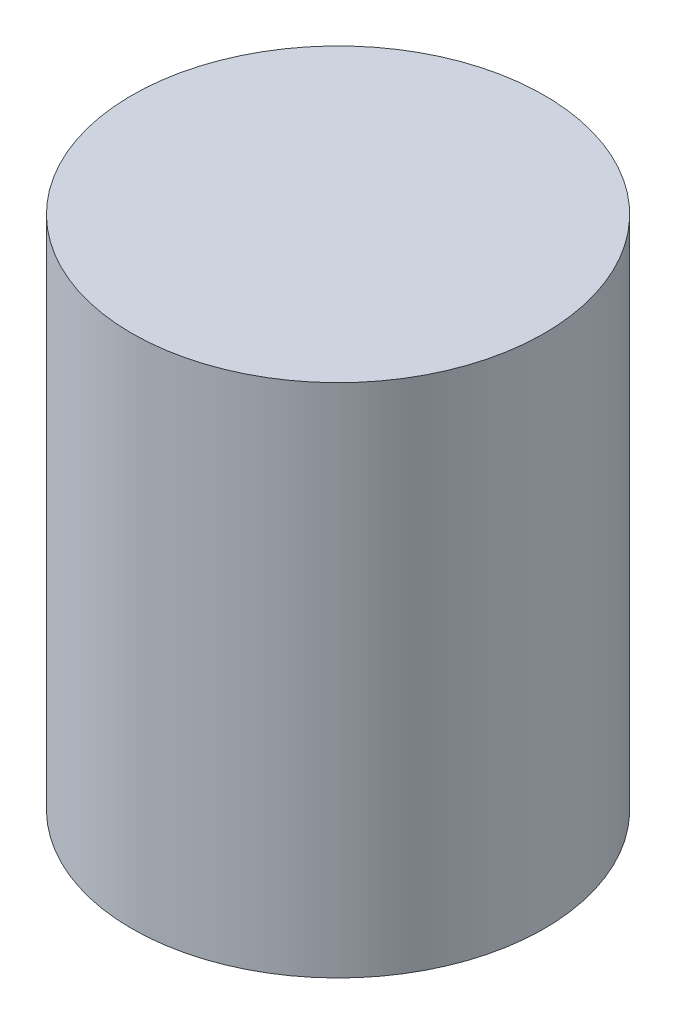
from build123d import *

# Parameters (mm, degrees)
SKETCH1_R           = 4
BOSS_EXTRUDE1_DEPTH = 5


with BuildPart() as part:
    # Sketch1 → Boss-Extrude1 (new body, symmetric)
    with BuildSketch(Plane(origin=(0, 0, 0), x_dir=(1, 0, 0), z_dir=(0, 1, 0))):
        Circle(SKETCH1_R)
    extrude(amount=BOSS_EXTRUDE1_DEPTH, both=True)


solid = part.part
